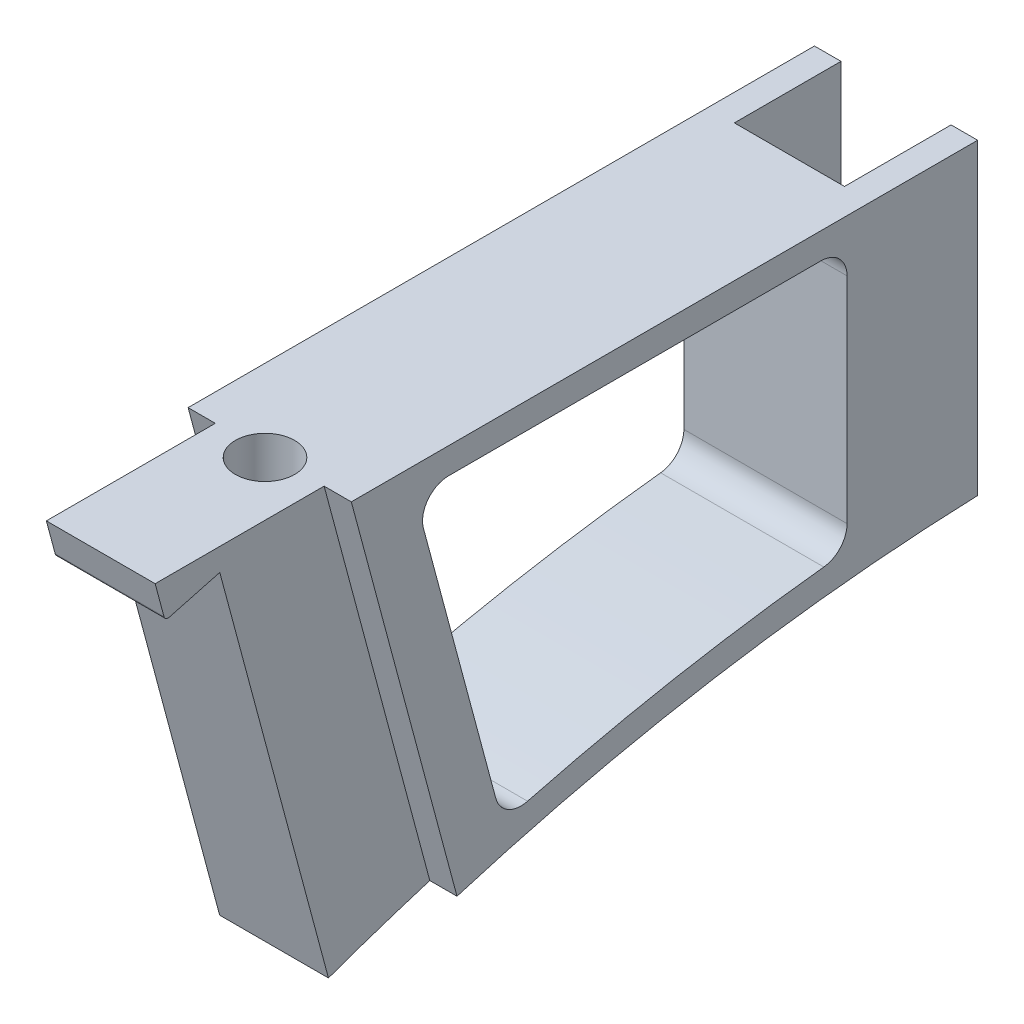
from build123d import *

# Parameters (mm, degrees)
BOSS_EXTRUDE1_DEPTH       = 4.7625
F_8_32_TAPPED_HOLE1_D     = 3.4544
F_8_32_TAPPED_HOLE1_DEPTH = 8.89
F_8_32_TAPPED_HOLE1_TIP   = 1.037806461
BOSS_EXTRUDE2_DEPTH       = 9.525
SKETCH5_W                 = 6.4262
SKETCH5_H                 = 22.225
CUT_EXTRUDE1_DEPTH        = 6.223
CUT_EXTRUDE2_DEPTH        = 1.5875
CUT_EXTRUDE4_DEPTH        = 5.7625
CUT_EXTRUDE4_DEPTH_BACK   = 5.7625
FILLET1_R                 = 1.524
BOSS_EXTRUDE3_DEPTH       = 6.35
FILLET2_R                 = 0.254
CUT_EXTRUDE5_DEPTH        = 8.9375


with BuildPart() as part:
    # Sketch1 → Boss-Extrude1 (new body, symmetric)
    with BuildSketch(Plane(origin=(0, 0, 0), x_dir=(0, 0, -1), z_dir=(1, 0, 0))):
        with BuildLine():
            Line((-18.389854, 0), (18.389854, 0))
            Line((18.389854, 0), (18.389854, -18.35404))
            ThreePointArc((18.389854, -18.35404), (3.13664885, -20.715801882), (-11.682560966, -25.031958383))
            Line((-11.682560966, -25.031958383), (-18.389854, 0))
        make_face()
    extrude(amount=BOSS_EXTRUDE1_DEPTH, both=True)

    # #8-32 Tapped Hole1
    with Locations(Plane(origin=(0, 0, 0), x_dir=(-1, 0, 0), z_dir=(0, 1, 0))):
        with Locations((0, 12.090146)):
            Hole(F_8_32_TAPPED_HOLE1_D / 2, depth=F_8_32_TAPPED_HOLE1_DEPTH)
            with Locations((0, 0, -(F_8_32_TAPPED_HOLE1_DEPTH + F_8_32_TAPPED_HOLE1_TIP / 2))):  # 118° drill point
                Cone(0, F_8_32_TAPPED_HOLE1_D / 2, F_8_32_TAPPED_HOLE1_TIP, mode=Mode.SUBTRACT)

    # Sketch4 → Boss-Extrude2 (add)
    with BuildSketch(Plane(origin=(4.7625, 0, 0), x_dir=(0, 0, -1), z_dir=(1, 0, 0))):
        with BuildLine():
            Line((18.389854, 0), (24.739854, 0))
            Line((24.739854, 0), (24.739854, -17.95993887))
            ThreePointArc((24.739854, -17.95993887), (21.562219751, -18.114544788), (18.389854, -18.35404))
            Line((18.389854, -18.35404), (18.389854, 0))
        make_face()
    extrude(amount=-BOSS_EXTRUDE2_DEPTH)

    # Sketch5 → Cut-Extrude1 (cut)
    with BuildSketch(Plane(origin=(0, 0, -24.739854), x_dir=(-1, 0, 0), z_dir=(0, 0, -1))):
        with Locations((0, -11.1125)):
            Rectangle(SKETCH5_W, SKETCH5_H)
    extrude(amount=-CUT_EXTRUDE1_DEPTH, mode=Mode.SUBTRACT)

    # Sketch6 → Cut-Extrude2 (cut)
    with BuildSketch(Plane(origin=(4.7625, -3.455581552, 12.676714301), x_dir=(0, -0.262996683, 0.964796738), z_dir=(-1, 0, 0))):
        with BuildLine():
            Line((4.603212059, 4.836470596), (-1.739365308, 3.107529419))
            Line((-1.739365308, 3.107529419), (-1.636225637, -20.725696455))
            ThreePointArc((-1.636225637, -20.725696455), (1.5419234, -20.859537189), (4.715359636, -21.078277005))
            Line((4.715359636, -21.078277005), (4.603212059, 4.836470596))
        make_face()
    cut_extrude2 = extrude(amount=CUT_EXTRUDE2_DEPTH, mode=Mode.SUBTRACT)

    # Mirror1: Cut-Extrude2 across plane
    add(cut_extrude2.mirror(Plane(origin=(0, 0, 0), x_dir=(0, 0, 1), z_dir=(1, 0, 0))), mode=Mode.SUBTRACT)

    # Sketch8 → Cut-Extrude4 (cut, two sides)
    with BuildSketch(Plane(origin=(0, 0, 0), x_dir=(0, 0, -1), z_dir=(1, 0, 0))) as cut_extrude4_sk:
        with BuildLine():
            Line((-8.120493812, -1.524), (17.119854, -1.524))
            Line((17.119854, -1.524), (17.119854, -16.942404249))
            ThreePointArc((17.119854, -16.942404249), (6.985210432, -18.377350774), (-2.991129125, -20.667049623))
            Line((-2.991129125, -20.667049623), (-8.120493812, -1.524))
        make_face()
    extrude(amount=CUT_EXTRUDE4_DEPTH, mode=Mode.SUBTRACT)
    extrude(cut_extrude4_sk.sketch, amount=-CUT_EXTRUDE4_DEPTH_BACK, mode=Mode.SUBTRACT)

    # Fillet1
    fillet1_edges = [part.edges().sort_by_distance(p)[0] for p in [
        (0, -20.667049623, 2.991129125),
        (0, -1.524, 8.120493812),
        (0, -1.524, -17.119854),
        (0, -16.942404249, -17.119854),
    ]]
    fillet(fillet1_edges, radius=FILLET1_R)

    # Sketch9 → Boss-Extrude3 (add)
    with BuildSketch(Plane(origin=(3.175, 0, 0), x_dir=(0, 0, -1), z_dir=(1, 0, 0))):
        Polygon((-18.389854, 0), (-21.676855873, 0), (-21.095098292, -2.171148848), (-18.028283794, -1.349398379), align=None)
    extrude(amount=-BOSS_EXTRUDE3_DEPTH)

    # Fillet2
    fillet2_edges = [part.edges().sort_by_distance(p)[0] for p in [
        (0, -2.171148848, 21.095098292),
    ]]
    fillet(fillet2_edges, radius=FILLET2_R)

    # Sketch13 → Cut-Extrude5 (cut, through all)
    with BuildSketch(Plane(origin=(3.175, 0, 0), x_dir=(0, 0, -1), z_dir=(1, 0, 0))):
        with BuildLine():
            Line((-17.905611214, -1.316528361), (-18.028283794, -1.349398379))
            Line((-18.028283794, -1.349398379), (-11.682560966, -25.031958383))
            ThreePointArc((-11.682560966, -25.031958383), (-11.622647023, -25.010220768), (-11.562721445, -24.988515246))
            Line((-11.562721445, -24.988515246), (-17.905611214, -1.316528361))
        make_face()
    extrude(amount=-CUT_EXTRUDE5_DEPTH, mode=Mode.SUBTRACT)


solid = part.part
